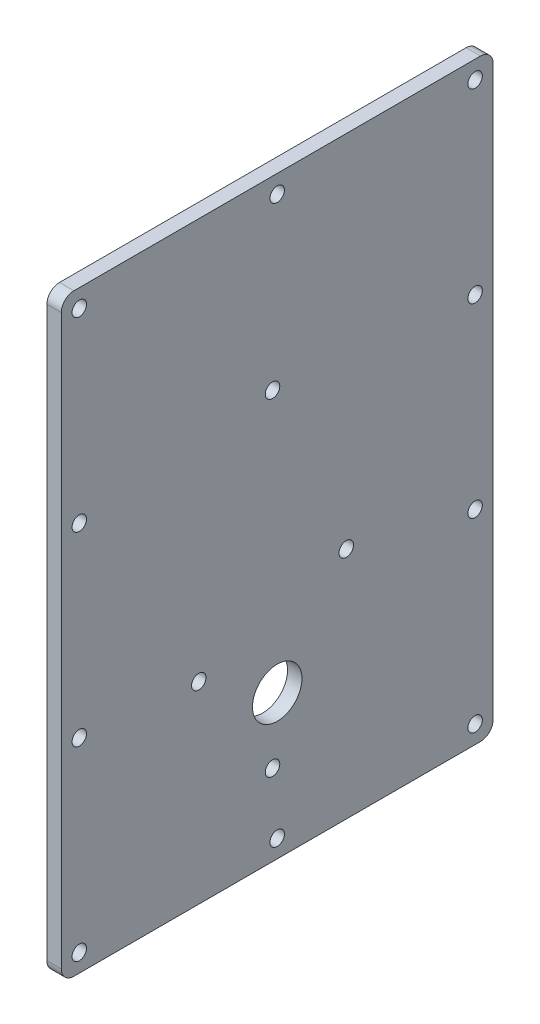
from build123d import *

# Parameters (mm, degrees)
SKETCH1_W              = 152.4
SKETCH1_H              = 209.55
BOSS_EXTRUDE2_DEPTH    = 5.08
SKETCH2_R              = 8.73125
CUT_EXTRUDE1_DEPTH     = 6.08
F_10_CLEARANCE_HOLE2_D = 5.1054
FILLET1_R              = 4.445
F_10_CLEARANCE_HOLE1_D = 5.1054


with BuildPart() as part:
    # Sketch1 → Boss-Extrude2 (new body)
    with BuildSketch(Plane(origin=(0, 0, 0), x_dir=(0, 0, -1), z_dir=(1, 0, 0))):
        with Locations((76.2, 104.775)):
            Rectangle(SKETCH1_W, SKETCH1_H)
    extrude(amount=BOSS_EXTRUDE2_DEPTH)

    # Sketch2 → Cut-Extrude1 (cut, through all)
    with BuildSketch(Plane(origin=(5.08, 0, 0), x_dir=(0, 0, -1), z_dir=(1, 0, 0))):
        with Locations((76.2, 50.8)):
            Circle(SKETCH2_R)
    extrude(amount=-CUT_EXTRUDE1_DEPTH, mode=Mode.SUBTRACT)

    # #10 Clearance Hole2 (through all)
    with Locations(Plane(origin=(5.08, 0, 0), x_dir=(0, 0, -1), z_dir=(1, 0, 0))):
        with Locations((48.520375625, 68.0466), (74.555375625, 144.106959494), (100.590375625, 82.55), (74.555375625, 28.575)):
            Hole(F_10_CLEARANCE_HOLE2_D / 2)

    # Fillet1
    fillet1_edges = [part.edges().sort_by_distance(p)[0] for p in [
        (2.54, 209.55, 0),
        (2.54, 209.55, -152.4),
        (2.54, 0, -152.4),
        (2.54, 0, 0),
    ]]
    fillet(fillet1_edges, radius=FILLET1_R)

    # #10 Clearance Hole1 (through all)
    with Locations(Plane(origin=(5.08, 0, 0), x_dir=(0, 0, -1), z_dir=(1, 0, 0))):
        with Locations((6.35, 203.2), (146.05, 6.35), (6.35, 6.35), (146.05, 203.2), (76.2, 6.35), (76.2, 203.2), (6.35, 137.583333333), (6.35, 71.966666667), (146.05, 71.966666667), (146.05, 137.583333333)):
            Hole(F_10_CLEARANCE_HOLE1_D / 2)


solid = part.part
